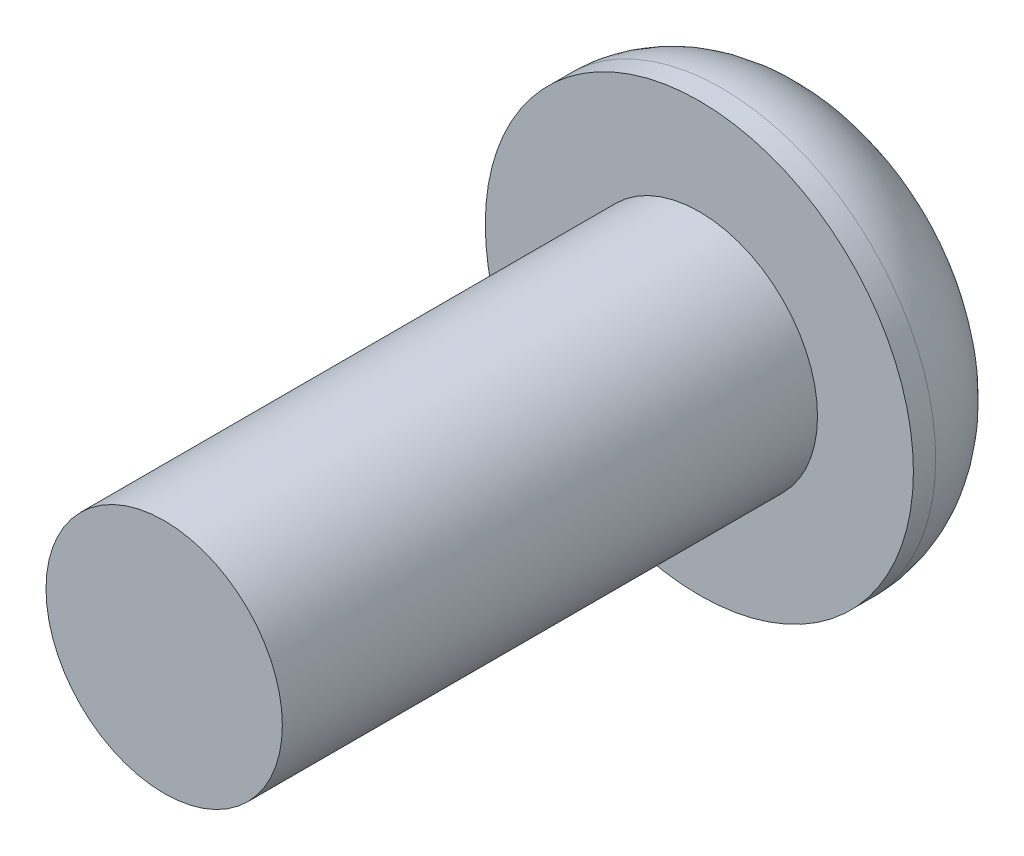
from build123d import *

# Parameters (mm, degrees)
SKETCH1_R      = 3.175
EXTRUDE1_DEPTH = 1.8542
FILLET1_R      = 1.524
SKETCH2_R      = 1.7526
EXTRUDE2_DEPTH = 7.9375
EXTRUDE3_DEPTH = 1.016


with BuildPart() as part:
    # Sketch1 → Extrude1 (new body)
    with BuildSketch(Plane.XY):
        Circle(SKETCH1_R)
    extrude(amount=EXTRUDE1_DEPTH)

    # Fillet1
    fillet1_edges = [part.edges().sort_by_distance(p)[0] for p in [
        (-3.175, 0, 0),
    ]]
    fillet(fillet1_edges, radius=FILLET1_R)

    # Sketch2 → Extrude2 (add)
    with BuildSketch(Plane.XY.offset(1.8542)):
        Circle(SKETCH2_R)
    extrude(amount=EXTRUDE2_DEPTH)

    # Sketch3 → Extrude3 (cut)
    with BuildSketch(Plane(origin=(0, 0, 0), x_dir=(-1, 0, 0), z_dir=(0, 0, -1))):
        Polygon((0.59085384, 0.981566666), (-0.554634748, 1.002477769), (-1.145488588, 0.020911103), (-0.59085384, -0.981566666), (0.554634748, -1.002477769), (1.145488588, -0.020911103), align=None)
    extrude(amount=-EXTRUDE3_DEPTH, mode=Mode.SUBTRACT)


solid = part.part
